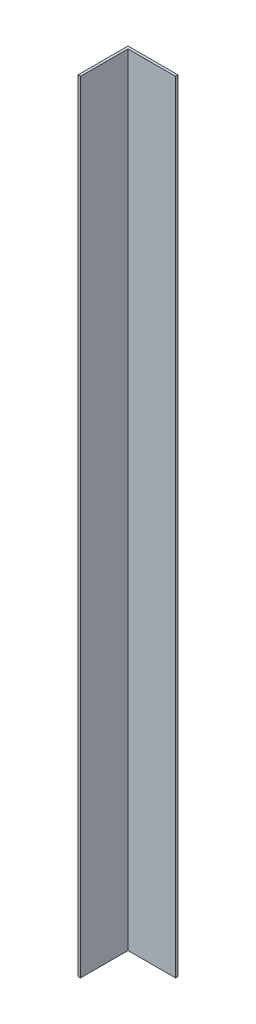
from build123d import *

# Parameters (mm, degrees)
BOSS_EXTRU_1_DEPTH = 624


with BuildPart() as part:
    # Esquisse1 → Boss.-Extru.1 (new body)
    with BuildSketch(Plane(origin=(0, 0, 0), x_dir=(1, 0, 0), z_dir=(0, 1, 0))):
        Polygon((-20, 20.113636364), (20, 20.113636364), (20, 18.113636364), (-18, 18.113636364), (-18, -19.886363636), (-20, -19.886363636), align=None)
    extrude(amount=BOSS_EXTRU_1_DEPTH)


solid = part.part
